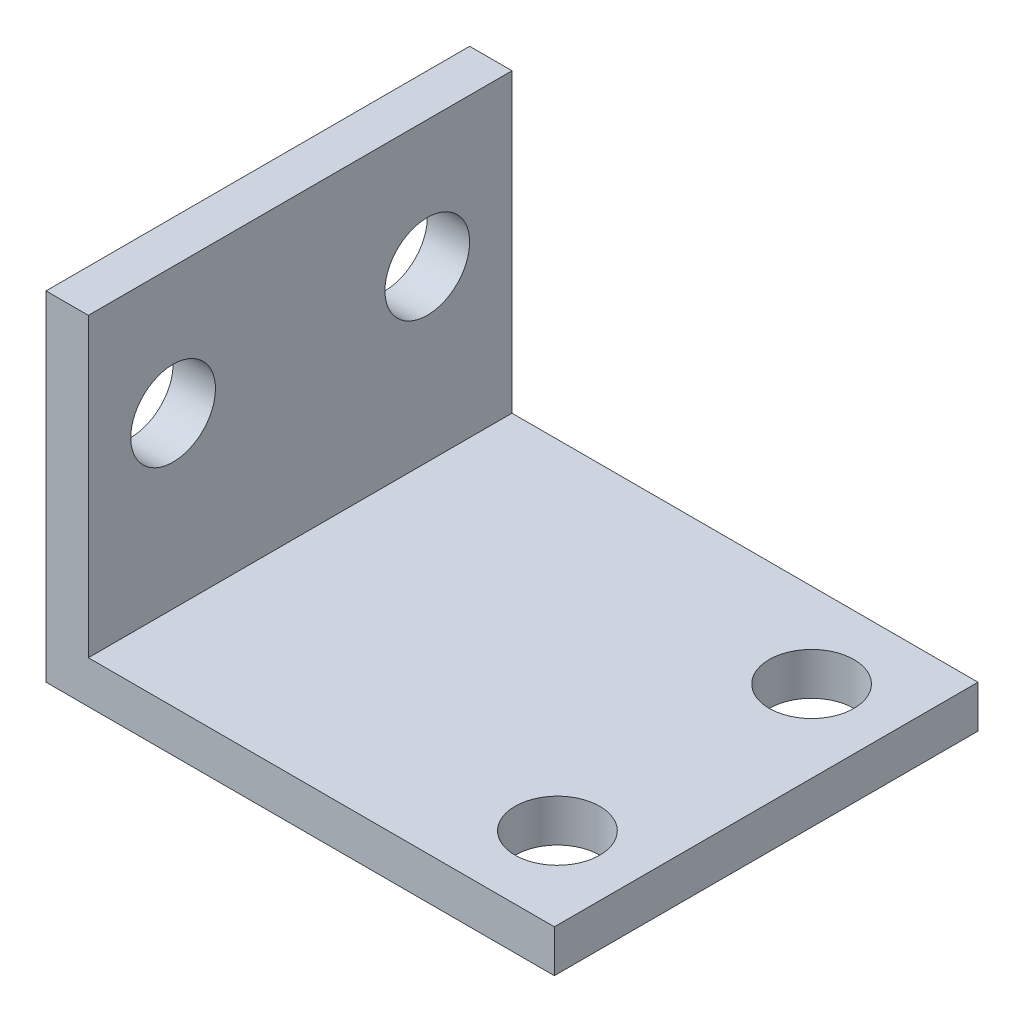
from build123d import *

# Parameters (mm, degrees)
BOSS_EXTRUDE1_DEPTH = 31.75
SKETCH2_R           = 3.175
CUT_EXTRUDE1_DEPTH  = 4.175
SKETCH3_R           = 3.175
CUT_EXTRUDE2_DEPTH  = 4.175


with BuildPart() as part:
    # Sketch1 → Boss-Extrude1 (new body)
    with BuildSketch(Plane.XY):
        Polygon((0, 0), (0, 25.4), (3.175, 25.4), (3.175, 3.175), (38.1, 3.175), (38.1, 0), align=None)
    extrude(amount=BOSS_EXTRUDE1_DEPTH)

    # Sketch2 → Cut-Extrude1 (cut, through all)
    with BuildSketch(Plane(origin=(0, 3.175, 0), x_dir=(1, 0, 0), z_dir=(0, 1, 0))):
        with Locations((31.9786, -6.35)):
            Circle(SKETCH2_R)
        with Locations((31.9786, -25.4)):
            Circle(SKETCH2_R)
    extrude(amount=-CUT_EXTRUDE1_DEPTH, mode=Mode.SUBTRACT)

    # Sketch3 → Cut-Extrude2 (cut, through all)
    with BuildSketch(Plane(origin=(3.175, 0, 0), x_dir=(0, 0, -1), z_dir=(1, 0, 0))):
        with Locations((-25.4, 15.875)):
            Circle(SKETCH3_R)
        with Locations((-6.35, 15.875)):
            Circle(SKETCH3_R)
    extrude(amount=-CUT_EXTRUDE2_DEPTH, mode=Mode.SUBTRACT)


solid = part.part
